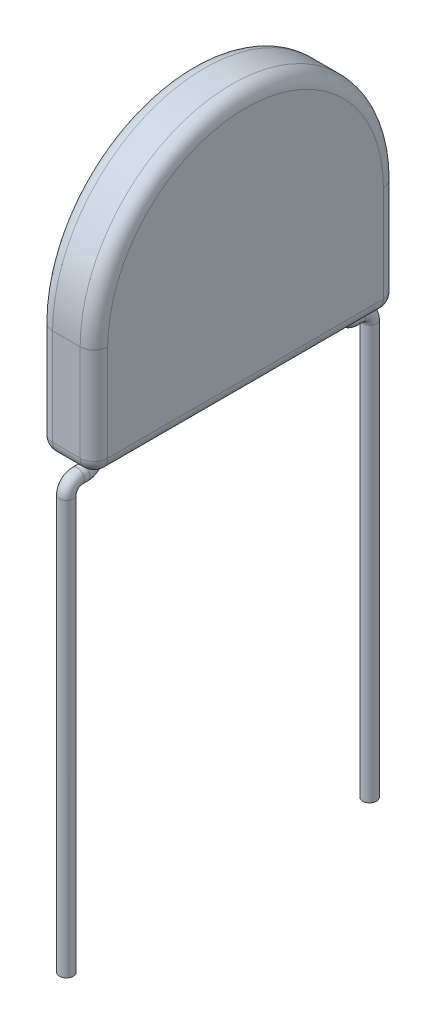
from build123d import *

# Parameters (mm, degrees)
BOSS_EXTRUDE1_DEPTH = 1
FILLET3_R           = 0.25
SKETCH3_R           = 0.125


with BuildPart() as part:
    # Sketch1 → Boss-Extrude1 (new body)
    with BuildSketch(Plane(origin=(0, 0, 0), x_dir=(0, 0, -1), z_dir=(1, 0, 0))):
        with BuildLine():
            Line((0, 2), (0, 0))
            Line((0, 0), (5.5, 0))
            Line((5.5, 0), (5.5, 2))
            ThreePointArc((5.5, 2), (2.75, 4.75), (0, 2))
        make_face()
    extrude(amount=BOSS_EXTRUDE1_DEPTH)

    # Fillet3
    fillet3_edges = [part.edges().sort_by_distance(p)[0] for p in [
        (1, 0, -2.75),
        (1, 1, -5.5),
        (1, 4.75, -2.75),
        (0, 1, -5.5),
        (0, 0, -2.75),
        (0, 1, 0),
        (0, 4.75, -2.75),
        (1, 1, 0),
        (0.5, 0, -5.5),
        (0.5, 0, 0),
    ]]
    fillet(fillet3_edges, radius=FILLET3_R)

    # Sweep1: sweep along a path in Sketch2
    with BuildLine(Plane(origin=(0.5, 0, 0), x_dir=(0, 0, -1), z_dir=(1, 0, 0))) as sweep1_path:
        Line((0.5, 0), (0.5, -0.05))
        ThreePointArc((0.5, -0.05), (0.441421356, -0.191421356), (0.3, -0.25))
        Line((0.3, -0.25), (0.2, -0.25))
        ThreePointArc((0.2, -0.25), (0.058578644, -0.308578644), (0, -0.45))
        Line((0, -0.45), (0, -7.95))
    # Sketch3 → Sweep1 (sweep)
    with BuildSketch(Plane.XZ):
        with Locations((0.5, -0.5)):
            Circle(SKETCH3_R)
    sweep1 = sweep(path=sweep1_path.line)

    # Mirror1: Sweep1 across plane
    add(sweep1.mirror(Plane.XY.offset(-2.75)))


solid = part.part
